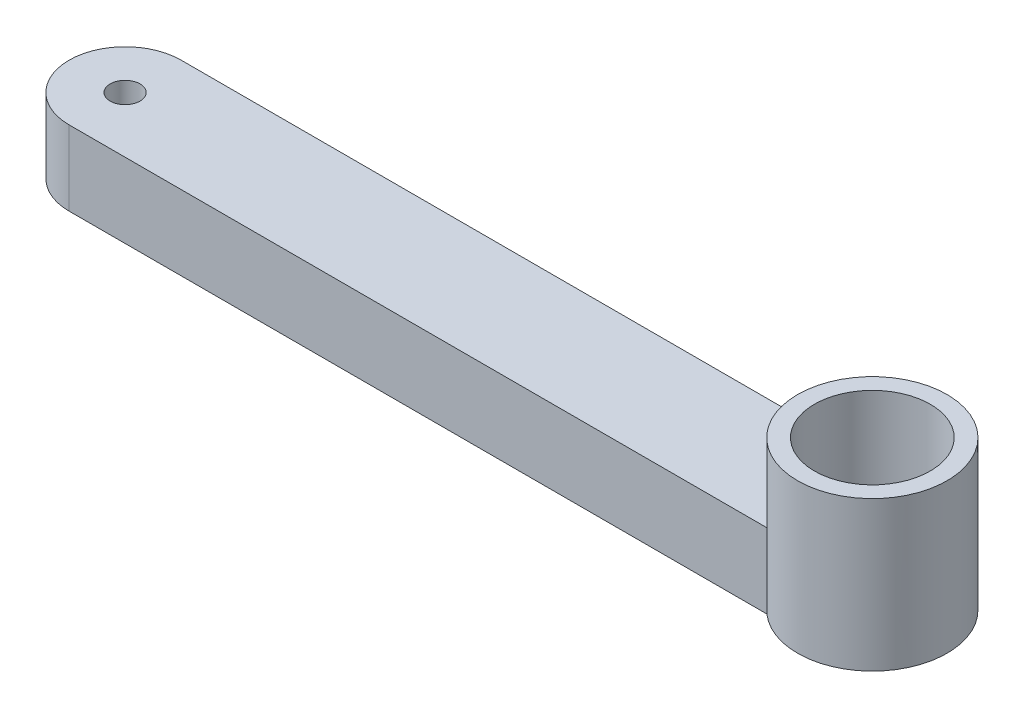
from build123d import *

# Parameters (mm, degrees)
SKETCH2_R           = 2
SKETCH2_R_2         = 2.5
BOSS_EXTRUDE1_DEPTH = 10
SKETCH3_R           = 10
BOSS_EXTRUDE3_DEPTH = 20
CUT_EXTRUDE1_REACH  = 22
SKETCH4_R           = 7.75


with BuildPart() as part:
    # Sketch2 → Boss-Extrude1 (new body)
    with BuildSketch(Plane(origin=(0, 0, 0), x_dir=(1, 0, 0), z_dir=(0, 1, 0))):
        with BuildLine():
            Line((0, 7.5), (100, 7.5))
            ThreePointArc((100, 7.5), (107.5, 0), (100, -7.5))
            Line((100, -7.5), (0, -7.5))
            ThreePointArc((0, -7.5), (-7.5, 0), (0, 7.5))
        make_face()
        Circle(SKETCH2_R, mode=Mode.SUBTRACT)
        with Locations((100, 0)):
            Circle(SKETCH2_R_2, mode=Mode.SUBTRACT)
    extrude(amount=BOSS_EXTRUDE1_DEPTH)

    # Sketch3 → Boss-Extrude3 (add)
    with BuildSketch(Plane(origin=(0, 0, 0), x_dir=(1, 0, 0), z_dir=(0, 1, 0))):
        with Locations((100, 0)):
            Circle(SKETCH3_R)
    extrude(amount=BOSS_EXTRUDE3_DEPTH)

    # Sketch4 → Cut-Extrude1 (cut, up to next)
    with BuildSketch(Plane(origin=(0, 20, 0), x_dir=(1, 0, 0), z_dir=(0, 1, 0)), mode=Mode.PRIVATE) as cut_extrude1_sk1:
        with Locations((100, 0)):
            Circle(SKETCH4_R)
    cut_extrude1_tool1 = extrude(cut_extrude1_sk1.sketch, amount=-CUT_EXTRUDE1_REACH, mode=Mode.PRIVATE) & part.part
    add(cut_extrude1_tool1.solids().sort_by_distance((100, 20, 0))[0], mode=Mode.SUBTRACT)


solid = part.part
